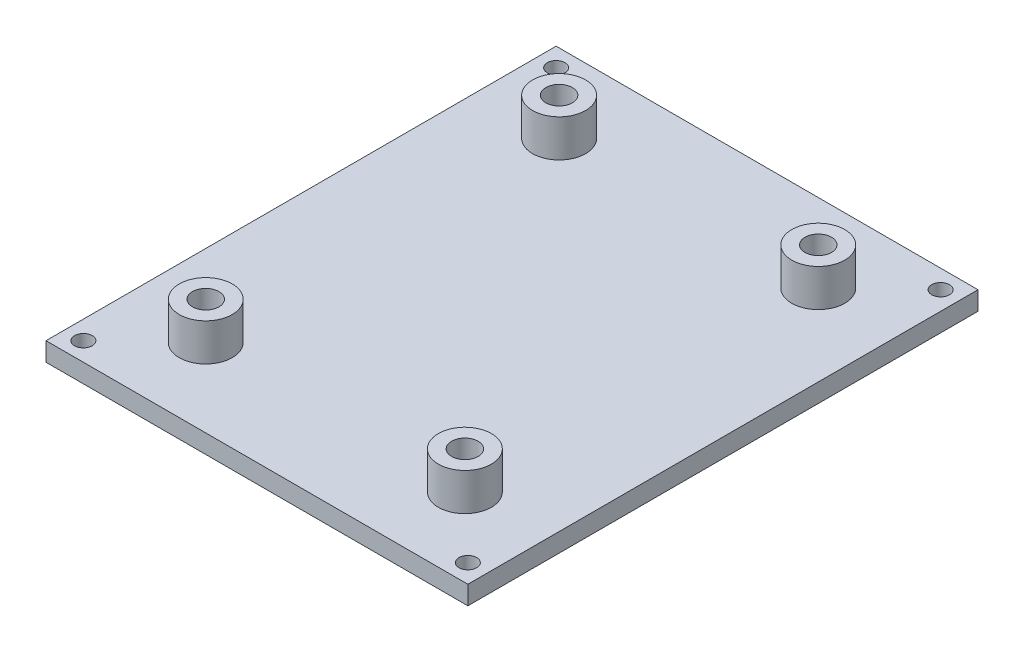
from build123d import *

# Parameters (mm, degrees)
SKETCH2_W                                  = 71.628
SKETCH2_H                                  = 86.614
BOSS_EXTRUDE1_DEPTH                        = 1.5875
CUT_EXTRUDE1_REACH                         = 58.287
SKETCH3_R                                  = 1.5
MIRROR1_AT_THE_SECOND_PLANE_COPY_1_REACH   = 58.287
MIRROR1_AT_THE_SECOND_PLANE_COPY_1_SKETC_R = 1.5
SKETCH4_R                                  = 4.500000017
SKETCH4_R_2                                = 2.2499955
BOSS_EXTRUDE2_DEPTH                        = 6.35
SKETCH4_3_R                                = 2.2499955
BOSS_EXTRUDE3_DEPTH                        = 0.549999916


with BuildPart() as part:
    # Sketch2 → Boss-Extrude1 (new, symmetric)
    with BuildSketch(Plane(origin=(0, 0, 0), x_dir=(1, 0, 0), z_dir=(0, 1, 0))):
        Rectangle(SKETCH2_W, SKETCH2_H)
    extrude(amount=BOSS_EXTRUDE1_DEPTH, both=True)

    # Sketch3 → Cut-Extrude1 (cut, up to next)
    with BuildSketch(Plane(origin=(0, 1.5875, 0), x_dir=(1, 0, 0), z_dir=(0, 1, 0)), mode=Mode.PRIVATE) as cut_extrude1_sk1:
        with Locations((-32.639, 40.132)):
            Circle(SKETCH3_R)
    cut_extrude1_tool1 = extrude(cut_extrude1_sk1.sketch, amount=-CUT_EXTRUDE1_REACH, mode=Mode.PRIVATE) & part.part
    cut_extrude1 = cut_extrude1_tool1.solids().sort_by_distance((-32.639, 1.5875, -40.132))[0]
    add(cut_extrude1, mode=Mode.SUBTRACT)

    # Mirror1: Cut-Extrude1 across plane
    add(cut_extrude1.mirror(Plane(origin=(0, 0, 0), x_dir=(0, 0, 1), z_dir=(1, 0, 0))), mode=Mode.SUBTRACT)

    # Mirror1 at the second plane: Cut-Extrude1 across plane
    add(cut_extrude1.mirror(Plane.XY), mode=Mode.SUBTRACT)

    # Mirror1 at the second plane copy 1 sketc → Mirror1 at the second plane copy 1 (cut, up to next)
    with BuildSketch(Plane(origin=(0, 1.5875, 0), x_dir=(-1, 0, 0), z_dir=(0, 1, 0)), mode=Mode.PRIVATE) as mirror1_at_the_second_plane_copy_1_sk1:
        with Locations((-32.639, 40.132)):
            Circle(MIRROR1_AT_THE_SECOND_PLANE_COPY_1_SKETC_R)
    mirror1_at_the_second_plane_copy_1_tool1 = extrude(mirror1_at_the_second_plane_copy_1_sk1.sketch, amount=-MIRROR1_AT_THE_SECOND_PLANE_COPY_1_REACH, mode=Mode.PRIVATE) & part.part
    add(mirror1_at_the_second_plane_copy_1_tool1.solids().sort_by_distance((32.639, 1.5875, 40.132))[0], mode=Mode.SUBTRACT)

    # Sketch4 → Boss-Extrude2 (add)
    # profile 1 of 4: a face of its own
    with BuildSketch(Plane(origin=(0, 1.5875, 0), x_dir=(1, 0, 0), z_dir=(0, 1, 0))):
        with Locations((-22, 30)):
            Circle(SKETCH4_R)
        with Locations((-22, 30)):
            Circle(SKETCH4_R_2, mode=Mode.SUBTRACT)
    # profile 2 of 4: a face of its own
    with BuildSketch(Plane(origin=(0, 1.5875, 0), x_dir=(1, 0, 0), z_dir=(0, 1, 0))):
        with Locations((22, 30)):
            Circle(SKETCH4_R)
        with Locations((22, 30)):
            Circle(SKETCH4_R_2, mode=Mode.SUBTRACT)
    # profile 3 of 4: a face of its own
    with BuildSketch(Plane(origin=(0, 1.5875, 0), x_dir=(1, 0, 0), z_dir=(0, 1, 0))):
        with Locations((-22, -30)):
            Circle(SKETCH4_R)
        with Locations((-22, -30)):
            Circle(SKETCH4_R_2, mode=Mode.SUBTRACT)
    # profile 4 of 4: a face of its own
    with BuildSketch(Plane(origin=(0, 1.5875, 0), x_dir=(1, 0, 0), z_dir=(0, 1, 0))):
        with Locations((22, -30)):
            Circle(SKETCH4_R)
        with Locations((22, -30)):
            Circle(SKETCH4_R_2, mode=Mode.SUBTRACT)
    extrude(amount=BOSS_EXTRUDE2_DEPTH)

    # Sketch4_3 → Boss-Extrude3 (add)
    with BuildSketch(Plane(origin=(0, 1.5875, 0), x_dir=(1, 0, 0), z_dir=(0, 1, 0))):
        with Locations((-22, 30)):
            Circle(SKETCH4_3_R)
        with Locations((22, 30)):
            Circle(SKETCH4_3_R)
        with Locations((-22, -30)):
            Circle(SKETCH4_3_R)
        with Locations((22, -30)):
            Circle(SKETCH4_3_R)
    extrude(amount=BOSS_EXTRUDE3_DEPTH)


solid = part.part
